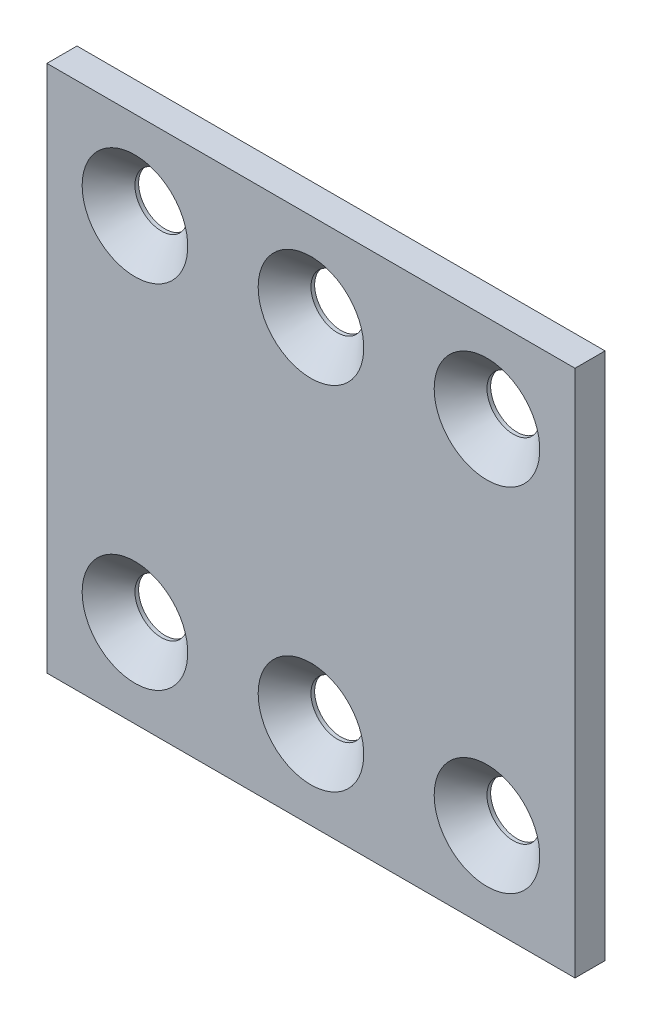
from build123d import *

# Parameters (mm, degrees)
SKETCH1_W           = 60
SKETCH1_H           = 60
BOSS_EXTRUDE1_DEPTH = 1.708
SKETCH2_R           = 3
CUT_EXTRUDE1_DEPTH  = 4.416
CHAMFER1_SIZE       = 3


with BuildPart() as part:
    # Sketch1 → Boss-Extrude1 (new body, symmetric)
    with BuildSketch(Plane.XY):
        Rectangle(SKETCH1_W, SKETCH1_H)
    extrude(amount=BOSS_EXTRUDE1_DEPTH, both=True)

    # Sketch2 → Cut-Extrude1 (cut, through all)
    with BuildSketch(Plane.XY.offset(1.708)):
        with Locations((0, 20)):
            Circle(SKETCH2_R)
        with Locations((0, -20)):
            Circle(SKETCH2_R)
        with Locations((20, -20)):
            Circle(SKETCH2_R)
        with Locations((-20, -20)):
            Circle(SKETCH2_R)
        with Locations((-20, 20)):
            Circle(SKETCH2_R)
        with Locations((20, 20)):
            Circle(SKETCH2_R)
    extrude(amount=-CUT_EXTRUDE1_DEPTH, mode=Mode.SUBTRACT)

    # Chamfer1
    chamfer1_edges = [part.edges().sort_by_distance(p)[0] for p in [
        (-3, -20, 1.708),
        (17, -20, 1.708),
        (-23, -20, 1.708),
        (-23, 20, 1.708),
        (17, 20, 1.708),
        (-3, 20, 1.708),
    ]]
    chamfer(chamfer1_edges, length=CHAMFER1_SIZE)


solid = part.part
